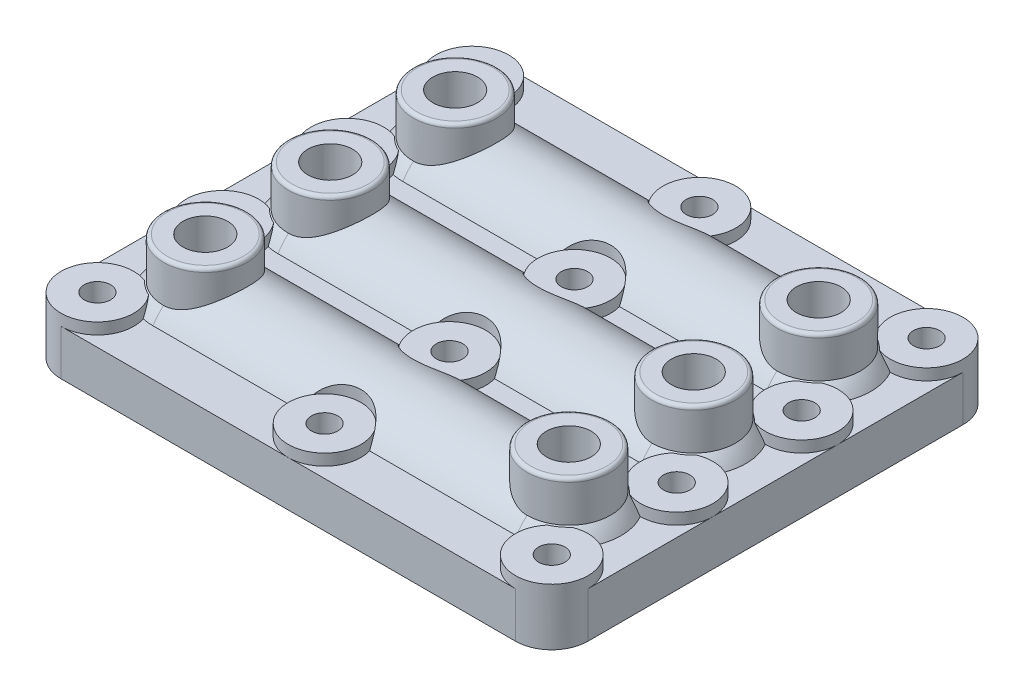
from build123d import *

# Parameters (mm, degrees)
BOSS_EXTRUDE1_DEPTH     = 1.5875
BOSS_EXTRUDE2_DEPTH     = 4.7625
INLET_OUTLET_POSTS_R    = 5.842
BOSS_EXTRUDE4_DEPTH     = 13.7795
REVOLVE2_ANGLE          = 180
LPATTERN1_COUNT         = 3
LPATTERN1_PITCH         = 17.4625
SKETCH22_R              = 5.08
BOSS_EXTRUDE5_DEPTH     = 1.5875
SKETCH23_R              = 5.08
CUT_EXTRUDE3_DEPTH      = 49.96427535
SKETCH24_R              = 1.8415
CUT_EXTRUDE4_DEPTH      = 49.96427535
SKETCH19_R              = 3.1242
CUT_EXTRUDE2_DEPTH      = 5.842
CUT_EXTRUDE1_DEPTH      = 0.93218
CUT_REVOLVE7_ANGLE      = 180
LPATTERN6_COUNT         = 3
LPATTERN6_PITCH         = 17.4625
SKETCH14_R              = 1.5875
CUT_REVOLVE8_ANGLE      = 90
LPATTERN7_COUNT         = 3
LPATTERN7_PITCH         = 17.4625
MIRROR1_COPY_1_SKETCH_R = 1.5875
MIRROR1_COPY_1_ANGLE    = 90
MIRROR1_COPY_2_SKETCH_R = 1.5875
MIRROR1_COPY_2_ANGLE    = 90
MIRROR1_COPY_3_SKETCH_R = 1.5875
MIRROR1_COPY_3_ANGLE    = 90
FILLET1_R               = 0.508
LPATTERN8_COUNT         = 3
LPATTERN8_PITCH         = 17.4625


with BuildPart() as part:
    # Footprint B → Boss-Extrude1 (new body)
    with BuildSketch(Plane(origin=(0, 0, 0), x_dir=(1, 0, 0), z_dir=(0, 1, 0))):
        with BuildLine():
            Line((31.75, 31.27375), (-31.75, 31.27375))
            ThreePointArc((-31.75, 31.27375), (-35.342102448, 29.785852448), (-36.83, 26.19375))
            Line((-36.83, 26.19375), (-36.83, -26.19375))
            ThreePointArc((-36.83, -26.19375), (-35.342102448, -29.785852448), (-31.75, -31.27375))
            Line((-31.75, -31.27375), (31.75, -31.27375))
            ThreePointArc((31.75, -31.27375), (35.342102448, -29.785852448), (36.83, -26.19375))
            Line((36.83, -26.19375), (36.83, 26.19375))
            ThreePointArc((36.83, 26.19375), (35.342102448, 29.785852448), (31.75, 31.27375))
        make_face()
    extrude(amount=BOSS_EXTRUDE1_DEPTH)

    # Main Body A → Boss-Extrude2 (add)
    with BuildSketch(Plane(origin=(0, 1.5875, 0), x_dir=(1, 0, 0), z_dir=(0, 1, 0))):
        with BuildLine():
            Line((-36.83, 26.19375), (-36.83, -26.19375))
            ThreePointArc((-36.83, -26.19375), (-35.342102448, -29.785852448), (-31.75, -31.27375))
            Line((-31.75, -31.27375), (31.75, -31.27375))
            ThreePointArc((31.75, -31.27375), (35.342102448, -29.785852448), (36.83, -26.19375))
            Line((36.83, -26.19375), (36.83, 26.19375))
            ThreePointArc((36.83, 26.19375), (35.342102448, 29.785852448), (31.75, 31.27375))
            Line((31.75, 31.27375), (-31.75, 31.27375))
            ThreePointArc((-31.75, 31.27375), (-35.342102448, 29.785852448), (-36.83, 26.19375))
        make_face()
    extrude(amount=BOSS_EXTRUDE2_DEPTH)

    # Inlet_outlet posts → Boss-Extrude4 (add)
    with BuildSketch(Plane(origin=(0, 0, 0), x_dir=(1, 0, 0), z_dir=(0, 1, 0))):
        with Locations((25.4, 17.4625)):
            Circle(INLET_OUTLET_POSTS_R)
        with Locations((25.4, 0)):
            Circle(INLET_OUTLET_POSTS_R)
        with Locations((25.4, -17.4625)):
            Circle(INLET_OUTLET_POSTS_R)
        with Locations((-25.4, -17.4625)):
            Circle(INLET_OUTLET_POSTS_R)
        with Locations((-25.4, 0)):
            Circle(INLET_OUTLET_POSTS_R)
        with Locations((-25.4, 17.4625)):
            Circle(INLET_OUTLET_POSTS_R)
    extrude(amount=BOSS_EXTRUDE4_DEPTH)

    # Sketch21 → Revolve2 (revolve)
    with BuildSketch(Plane(origin=(0, 1.5875, 0), x_dir=(-1, 0, 0), z_dir=(0, 1, 0))):
        with BuildLine():
            Line((25.4, -8.73125), (-25.4, -8.73125))
            ThreePointArc((-25.4, -8.73125), (-31.573926083, -11.288573917), (-34.13125, -17.4625))
            Line((-34.13125, -17.4625), (34.13125, -17.4625))
            ThreePointArc((34.13125, -17.4625), (31.573926083, -11.288573917), (25.4, -8.73125))
        make_face()
    revolve2 = revolve(axis=Axis((41.047323499, 1.5875, -17.4625), (-1, 0, 0)), revolution_arc=REVOLVE2_ANGLE)

    # LPattern1: Revolve2 ×3
    with Locations(*[(0, 0, i * LPATTERN1_PITCH) for i in range(1, LPATTERN1_COUNT)]):
        add(revolve2)

    # Sketch22 → Boss-Extrude5 (add)
    with BuildSketch(Plane(origin=(0, 6.35, 0), x_dir=(1, 0, 0), z_dir=(0, 1, 0))):
        with Locations((-31.75, 26.19375)):
            Circle(SKETCH22_R)
        with Locations((-31.75, 8.73125)):
            Circle(SKETCH22_R)
        with Locations((-31.75, -8.73125)):
            Circle(SKETCH22_R)
        with Locations((-31.75, -26.19375)):
            Circle(SKETCH22_R)
        with Locations((0, -26.19375)):
            Circle(SKETCH22_R)
        with Locations((0, -8.73125)):
            Circle(SKETCH22_R)
        with Locations((0, 8.73125)):
            Circle(SKETCH22_R)
        with Locations((0, 26.19375)):
            Circle(SKETCH22_R)
        with Locations((31.75, 26.19375)):
            Circle(SKETCH22_R)
        with Locations((31.75, 8.73125)):
            Circle(SKETCH22_R)
        with Locations((31.75, -8.73125)):
            Circle(SKETCH22_R)
        with Locations((31.75, -26.19375)):
            Circle(SKETCH22_R)
    extrude(amount=BOSS_EXTRUDE5_DEPTH)

    # Sketch23 → Cut-Extrude3 (cut, through all)
    with BuildSketch(Plane(origin=(0, 7.9375, 0), x_dir=(1, 0, 0), z_dir=(0, 1, 0))):
        with Locations((0, -26.19375)):
            Circle(SKETCH23_R)
        with Locations((0, -8.73125)):
            Circle(SKETCH23_R)
        with Locations((0, 8.73125)):
            Circle(SKETCH23_R)
        with Locations((0, 26.19375)):
            Circle(SKETCH23_R)
    extrude(amount=CUT_EXTRUDE3_DEPTH, mode=Mode.SUBTRACT)

    # Sketch24 → Cut-Extrude4 (cut, through all)
    with BuildSketch(Plane(origin=(0, 7.9375, 0), x_dir=(1, 0, 0), z_dir=(0, 1, 0))):
        with Locations((-31.75, 26.19375)):
            Circle(SKETCH24_R)
        with Locations((-31.75, 8.73125)):
            Circle(SKETCH24_R)
        with Locations((-31.75, -8.73125)):
            Circle(SKETCH24_R)
        with Locations((-31.75, -26.19375)):
            Circle(SKETCH24_R)
        with Locations((0, 26.19375)):
            Circle(SKETCH24_R)
        with Locations((0, 8.73125)):
            Circle(SKETCH24_R)
        with Locations((0, -8.73125)):
            Circle(SKETCH24_R)
        with Locations((0, -26.19375)):
            Circle(SKETCH24_R)
        with Locations((31.75, 26.19375)):
            Circle(SKETCH24_R)
        with Locations((31.75, 8.73125)):
            Circle(SKETCH24_R)
        with Locations((31.75, -8.73125)):
            Circle(SKETCH24_R)
        with Locations((31.75, -26.19375)):
            Circle(SKETCH24_R)
    extrude(amount=-CUT_EXTRUDE4_DEPTH, mode=Mode.SUBTRACT)

    # Sketch19 → Cut-Extrude2 (cut)
    with BuildSketch(Plane(origin=(0, 13.7795, 0), x_dir=(1, 0, 0), z_dir=(0, 1, 0))):
        with Locations((-25.4, 17.4625)):
            Circle(SKETCH19_R)
        with Locations((-25.4, 0)):
            Circle(SKETCH19_R)
        with Locations((-25.4, -17.4625)):
            Circle(SKETCH19_R)
        with Locations((25.4, 17.4625)):
            Circle(SKETCH19_R)
        with Locations((25.4, 0)):
            Circle(SKETCH19_R)
        with Locations((25.4, -17.4625)):
            Circle(SKETCH19_R)
    extrude(amount=-CUT_EXTRUDE2_DEPTH, mode=Mode.SUBTRACT)

    # Gas Channel → Cut-Extrude1 (cut)
    with BuildSketch(Plane(origin=(0, 0, 0), x_dir=(1, 0, 0), z_dir=(0, 1, 0))):
        with BuildLine():
            Line((-19.05, 19.70756403), (19.05, 19.70756403))
            ThreePointArc((19.05, 19.70756403), (21.29506403, 17.4625), (19.05, 15.21743597))
            Line((19.05, 15.21743597), (-19.05, 15.21743597))
            ThreePointArc((-19.05, 15.21743597), (-21.29506403, 17.4625), (-19.05, 19.70756403))
        make_face()
    cut_extrude1 = extrude(amount=CUT_EXTRUDE1_DEPTH, mode=Mode.SUBTRACT)

    # Sketch13 → Cut-Revolve7 (revolve, cut)
    with BuildSketch(Plane.XZ.offset(-0.93218)):
        with BuildLine():
            Line((-19.05, -19.70756403), (19.05, -19.70756403))
            ThreePointArc((19.05, -19.70756403), (20.6375, -19.05), (21.29506403, -17.4625))
            Line((21.29506403, -17.4625), (-21.29506403, -17.4625))
            ThreePointArc((-21.29506403, -17.4625), (-20.6375, -19.05), (-19.05, -19.70756403))
        make_face()
    cut_revolve7 = revolve(axis=Axis((-22.011141991, 0.93218, -17.4625), (1, 0, 0)), revolution_arc=CUT_REVOLVE7_ANGLE, mode=Mode.SUBTRACT)

    # LPattern6: Cut-Extrude1, Cut-Revolve7 ×3
    with Locations(*[(0, 0, i * LPATTERN6_PITCH) for i in range(1, LPATTERN6_COUNT)]):
        add(cut_extrude1, mode=Mode.SUBTRACT)
        add(cut_revolve7, mode=Mode.SUBTRACT)

    # Sketch14 → Cut-Revolve8 (revolve, cut)
    with BuildSketch(Plane(origin=(19.05, 0, 0), x_dir=(0, 0, -1), z_dir=(1, 0, 0))):
        with Locations((17.4625, 1.5875)):
            Circle(SKETCH14_R)
    cut_revolve8 = revolve(axis=Axis((19.05, 7.9375, -12.915188309), (0, 0, 1)), revolution_arc=CUT_REVOLVE8_ANGLE, mode=Mode.SUBTRACT)

    # LPattern7: Cut-Revolve8 ×3
    with Locations(*[(0, 0, i * LPATTERN7_PITCH) for i in range(1, LPATTERN7_COUNT)]):
        add(cut_revolve8, mode=Mode.SUBTRACT)

    # Mirror1 copy 1 sketch → Mirror1 copy 1 (revolve, cut)
    with BuildSketch(Plane(origin=(-19.05, 0, 17.4625), x_dir=(0, 0, -1), z_dir=(-1, 0, 0))):
        with Locations((17.4625, -1.5875)):
            Circle(MIRROR1_COPY_1_SKETCH_R)
    revolve(axis=Axis((-19.05, 7.9375, 4.547311691), (0, 0, -1)), revolution_arc=MIRROR1_COPY_1_ANGLE, mode=Mode.SUBTRACT)

    # Mirror1 copy 2 sketch → Mirror1 copy 2 (revolve, cut)
    with BuildSketch(Plane(origin=(-19.05, 0, 34.925), x_dir=(0, 0, -1), z_dir=(-1, 0, 0))):
        with Locations((17.4625, -1.5875)):
            Circle(MIRROR1_COPY_2_SKETCH_R)
    revolve(axis=Axis((-19.05, 7.9375, 22.009811691), (0, 0, -1)), revolution_arc=MIRROR1_COPY_2_ANGLE, mode=Mode.SUBTRACT)

    # Mirror1 copy 3 sketch → Mirror1 copy 3 (revolve, cut)
    with BuildSketch(Plane(origin=(-19.05, 0, 0), x_dir=(0, 0, -1), z_dir=(-1, 0, 0))):
        with Locations((17.4625, -1.5875)):
            Circle(MIRROR1_COPY_3_SKETCH_R)
    revolve(axis=Axis((-19.05, 7.9375, -12.915188309), (0, 0, -1)), revolution_arc=MIRROR1_COPY_3_ANGLE, mode=Mode.SUBTRACT)

    # Fillet1
    fillet1_edges = [part.edges().sort_by_distance(p)[0] for p in [
        (19.558, 13.7795, 17.4625),
        (-31.242, 13.7795, 17.4625),
        (-31.242, 13.7795, 0),
        (19.558, 13.7795, 0),
        (19.558, 13.7795, -17.4625),
        (-31.242, 13.7795, -17.4625),
    ]]
    fillet(fillet1_edges, radius=FILLET1_R)

    # Cut-Sweep1: sweep along a path in Sketch25
    with BuildLine(Plane.XZ) as cut_sweep1_path:
        Line((-23.672876583, -12.672842985), (23.672876583, -12.672842985))
        ThreePointArc((23.672876583, -12.672842985), (28.462533598, -17.4625), (23.672876583, -22.252157015))
        Line((23.672876583, -22.252157015), (-23.672876583, -22.252157015))
        ThreePointArc((-23.672876583, -22.252157015), (-28.462533598, -17.4625), (-23.672876583, -12.672842985))
    # Sketch27 → Cut-Sweep1 (sweep, cut)
    with BuildSketch(Plane(origin=(0, 0, 0), x_dir=(0, 0, -1), z_dir=(1, 0, 0))):
        with BuildLine():
            Line((13.561842985, -0.498676329), (12.672842985, -0.498676329))
            Line((12.672842985, -0.498676329), (12.672842985, 0.390323671))
            ThreePointArc((12.672842985, 0.390323671), (14.190460913, 1.018941599), (13.561842985, -0.498676329))
        make_face()
    cut_sweep1 = sweep(path=cut_sweep1_path.line, mode=Mode.SUBTRACT)

    # LPattern8: Cut-Sweep1 ×3
    with Locations(*[(0, 0, i * LPATTERN8_PITCH) for i in range(1, LPATTERN8_COUNT)]):
        add(cut_sweep1, mode=Mode.SUBTRACT)


solid = part.part
